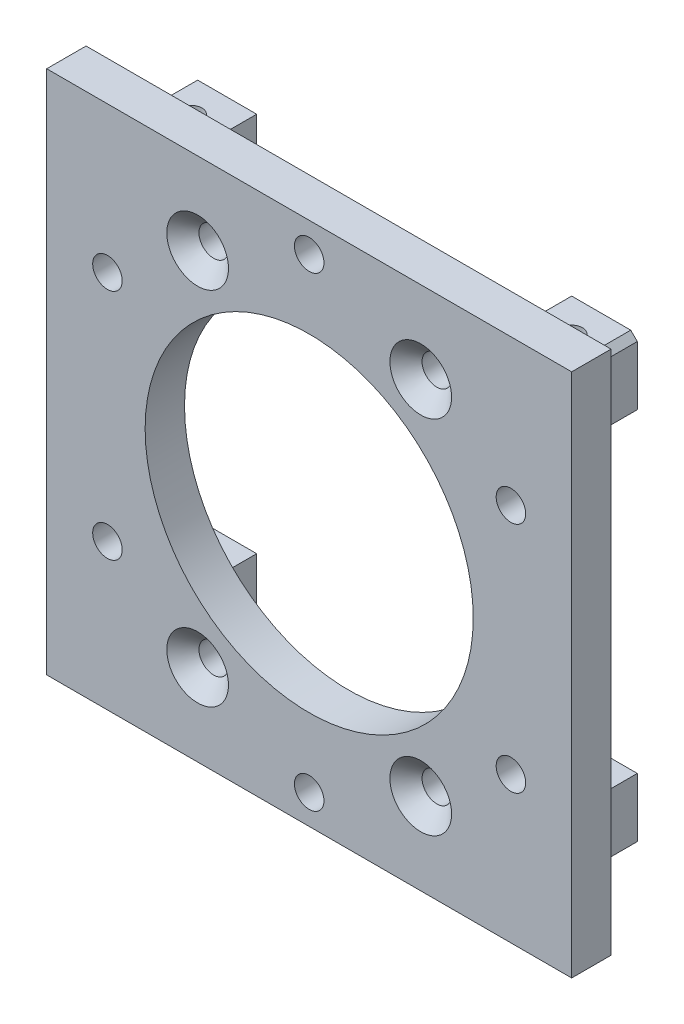
from build123d import *

# Parameters (mm, degrees)
SKETCH_1_W                     = 80
SKETCH_1_H                     = 80
SKETCH_1_R                     = 25
EXTRUDE_1_DEPTH                = 6
SKETCH_11_W                    = 10
SKETCH_11_H                    = 10
EXTRUDE_3_DEPTH                = 10
HOLE_WIZARD_M4_1_D             = 4.5
HOLE_WIZARD_M4_1_CSINK_D       = 8.96
HOLE_WIZARD_M4_1_CSINK_ANGLE   = 90
HOLE_WIZARD_M4_2_D             = 3.3
HOLE_WIZARD_M4_2_DEPTH         = 68
MIRROR_2_COPY_1_SKETCH_W       = 10
MIRROR_2_COPY_1_SKETCH_H       = 10
MIRROR_2_COPY_1_DEPTH          = 10
MIRROR_2_COPY_2_D              = 3.3
MIRROR_2_COPY_2_DEPTH          = 68
HOLE_WIZARD_M4_1_2_D           = 4.5
HOLE_WIZARD_M4_1_2_CSINK_D     = 9.4
HOLE_WIZARD_M4_1_2_CSINK_ANGLE = 90
CHAMFER_1_SIZE                 = 1


with BuildPart() as part:
    # 스케치1 → 보스-돌출1 (new body)
    with BuildSketch(Plane.XY):
        Rectangle(SKETCH_1_W, SKETCH_1_H)
        Circle(SKETCH_1_R, mode=Mode.SUBTRACT)
    extrude(amount=EXTRUDE_1_DEPTH)

    # 스케치11 → 보스-돌출3 (add)
    with BuildSketch(Plane(origin=(0, 0, 0), x_dir=(-1, 0, 0), z_dir=(0, 0, -1))):
        with Locations((29, 29)):
            Rectangle(SKETCH_11_W, SKETCH_11_H)
    extrude_3 = extrude(amount=EXTRUDE_3_DEPTH)

    # Hole Wizard M4 _ _ _ _ _ _ _1 (through all)
    with Locations(Plane(origin=(0, 0, 0), x_dir=(-1, 0, 0), z_dir=(0, 0, -1))):
        with Locations((0, -35.5), (30.743901834, -17.75), (30.743901834, 17.75), (0, 35.5), (-30.743901834, 17.75), (-30.743901834, -17.75)):
            CounterSinkHole(HOLE_WIZARD_M4_1_D / 2, HOLE_WIZARD_M4_1_CSINK_D / 2, counter_sink_angle=HOLE_WIZARD_M4_1_CSINK_ANGLE)

    # M4 나사 구멍2
    with Locations(Plane(origin=(0, 34, 0), x_dir=(1, 0, 0), z_dir=(0, 1, 0))):
        with Locations((-29, 5)):
            hole_wizard_m4_2 = Hole(HOLE_WIZARD_M4_2_D / 2, depth=HOLE_WIZARD_M4_2_DEPTH)

    # 대칭 복사1: 보스-돌출3, M4 나사 구멍2 across plane
    add(extrude_3.mirror(Plane(origin=(0, 0, 0), x_dir=(0, 0, 1), z_dir=(1, 0, 0))))
    add(hole_wizard_m4_2.mirror(Plane(origin=(0, 0, 0), x_dir=(0, 0, 1), z_dir=(1, 0, 0))), mode=Mode.SUBTRACT)

    # 대칭 복사2: 보스-돌출3, M4 나사 구멍2 across plane
    add(extrude_3.mirror(Plane.ZX))
    add(hole_wizard_m4_2.mirror(Plane.ZX), mode=Mode.SUBTRACT)

    # 대칭 복사2 copy 1 sketch → 대칭 복사2 copy 1 (add)
    with BuildSketch(Plane(origin=(0, 0, 0), x_dir=(1, 0, 0), z_dir=(0, 0, -1))):
        with Locations((29, 29)):
            Rectangle(MIRROR_2_COPY_1_SKETCH_W, MIRROR_2_COPY_1_SKETCH_H)
    extrude(amount=MIRROR_2_COPY_1_DEPTH)

    # 대칭 복사2 copy 2
    with Locations(Plane(origin=(0, -34, 0), x_dir=(-1, 0, 0), z_dir=(0, -1, 0))):
        with Locations((-29, 5)):
            Hole(MIRROR_2_COPY_2_D / 2, depth=MIRROR_2_COPY_2_DEPTH)

    # Hole Wizard M4 _ _ _ _1 2 (through all)
    with Locations(Plane.XY.offset(6)):
        with Locations((17, 27.5), (17, -27.5), (-17, 27.5), (-17, -27.5)):
            CounterSinkHole(HOLE_WIZARD_M4_1_2_D / 2, HOLE_WIZARD_M4_1_2_CSINK_D / 2, counter_sink_angle=HOLE_WIZARD_M4_1_2_CSINK_ANGLE)

    # 모따기1
    chamfer_1_edges = [part.edges().sort_by_distance(p)[0] for p in [
        (-34, -34, -5),
        (-34, 34, -5),
        (34, 34, -5),
        (34, -34, -5),
    ]]
    chamfer(chamfer_1_edges, length=CHAMFER_1_SIZE)


solid = part.part
